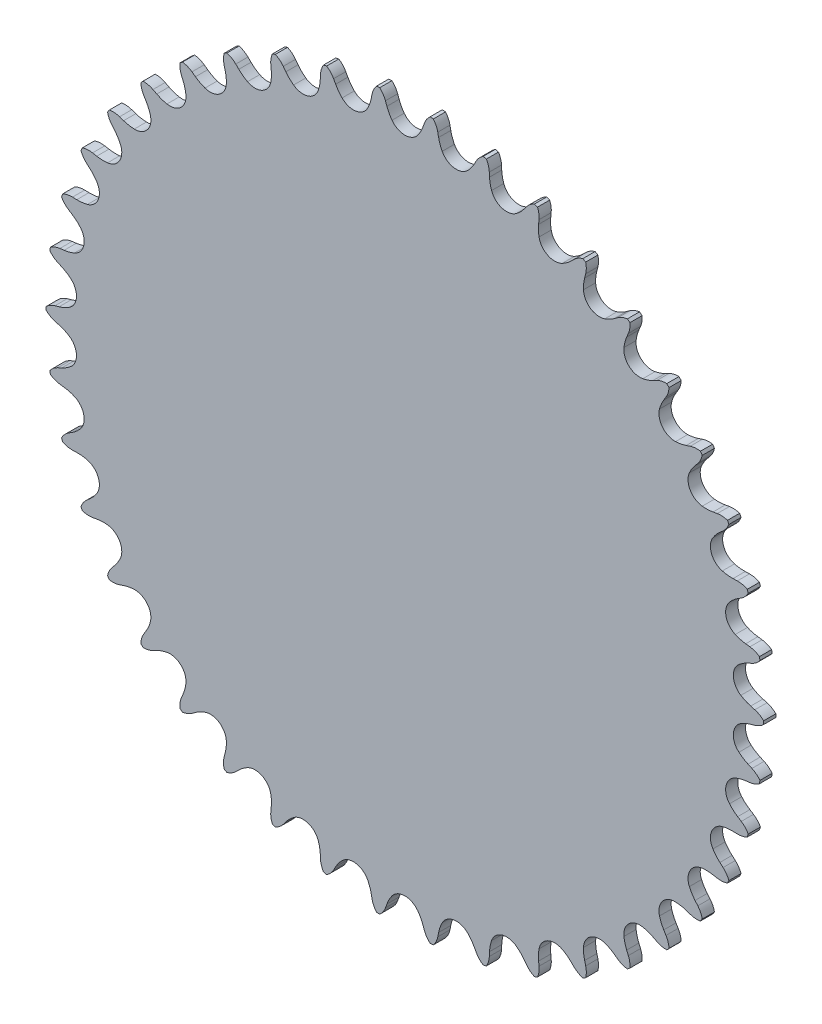
from build123d import *

# Parameters (mm, degrees)
SKETCH_3_R               = 88.259111261
EXTRUDE_2_DEPTH          = 3
CUT_EXTRUDE_3_DEPTH      = 4
PATTERN_CIRCULAR_1_COUNT = 42


with BuildPart() as part:
    # Sketch 3 → Extrude 2 (new body)
    with BuildSketch(Plane.XY):
        Circle(SKETCH_3_R)
    extrude(amount=EXTRUDE_2_DEPTH)

    # Sketch 4 → Cut-Extrude 3 (cut, through all)
    with BuildSketch(Plane.XY.offset(3)):
        with BuildLine():
            Line((-4.42402997, 84.972461498), (-4.783994684, 85.96273663))
            ThreePointArc((-4.783994684, 85.96273663), (-5.361044006, 87.090344724), (-6.19789386, 88.041222347))
            ThreePointArc((-6.19789386, 88.041222347), (0, 88.259111261), (6.19789386, 88.041222347))
            ThreePointArc((6.19789386, 88.041222347), (5.359222429, 87.091281653), (4.780288555, 85.964075966))
            Line((4.780288555, 85.964075966), (4.42402997, 84.972461498))
            ThreePointArc((4.42402997, 84.972461498), (3.884149716, 83.755790802), (3.173635368, 82.630212003))
            ThreePointArc((3.173635368, 82.630212003), (0, 81.028086498), (-3.173635368, 82.630212003))
            ThreePointArc((-3.173635368, 82.630212003), (-3.884149716, 83.755790802), (-4.42402997, 84.972461498))
        make_face()
    cut_extrude_3 = extrude(amount=-CUT_EXTRUDE_3_DEPTH, mode=Mode.SUBTRACT)

    # Pattern Circular 1: Cut-Extrude 3 ×42 about axis
    pattern_circular_1_axis = Axis((0, 0, 0), (0, 0, 1))
    for i in range(1, PATTERN_CIRCULAR_1_COUNT):
        add(cut_extrude_3.rotate(pattern_circular_1_axis, i * 360 / PATTERN_CIRCULAR_1_COUNT), mode=Mode.SUBTRACT)


solid = part.part
